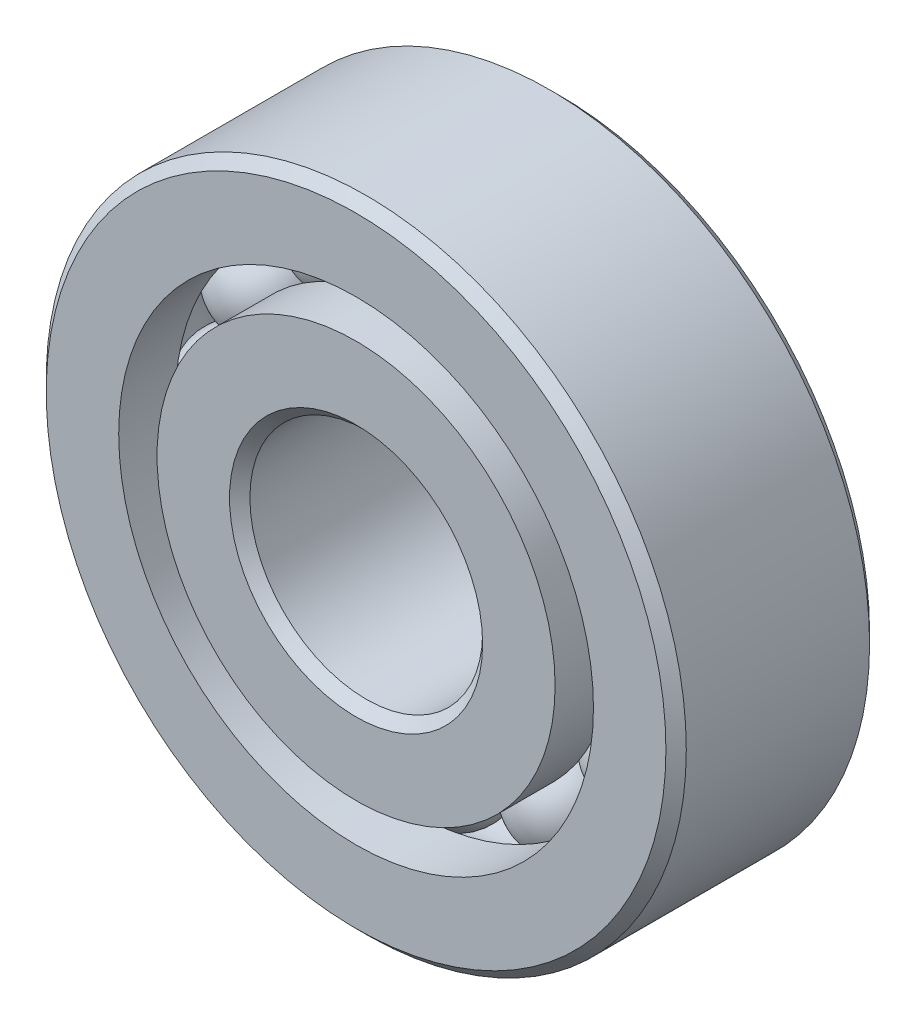
from build123d import *

# Parameters (mm, degrees)
CIRPATTERN1_COUNT = 12


with BuildPart() as part:
    # Sketch1 → Revolve1 (revolve)
    with BuildSketch(Plane(origin=(0, 0, 0), x_dir=(0, 0, -1), z_dir=(1, 0, 0))):
        with BuildLine():
            Line((3.15, 11), (-3.15, 11))
            Line((-3.15, 11), (-3.5, 10.65))
            Line((-3.5, 10.65), (-3.5, 8.159340659))
            Line((-3.5, 8.159340659), (-1.555555556, 8.159340659))
            ThreePointArc((-1.555555556, 8.159340659), (0, 9.189521587), (1.555555556, 8.159340659))
            Line((1.555555556, 8.159340659), (3.5, 8.159340659))
            Line((3.5, 8.159340659), (3.5, 10.65))
            Line((3.5, 10.65), (3.15, 11))
        make_face()
    revolve(axis=Axis((0, 0, 3.5), (0, 0, -1)))


with BuildPart() as body_2:
    # Sketch3 → Revolve3 (revolve)
    with BuildSketch(Plane(origin=(0, 0, 0), x_dir=(0, 0, -1), z_dir=(1, 0, 0))):
        with BuildLine():
            Line((-3.5, 6.840659341), (-1.555555556, 6.840659341))
            ThreePointArc((-1.555555556, 6.840659341), (0, 5.810478413), (1.555555556, 6.840659341))
            Line((1.555555556, 6.840659341), (3.5, 6.840659341))
            Line((3.5, 6.840659341), (3.5, 4.35))
            Line((3.5, 4.35), (3.15, 4))
            Line((3.15, 4), (-3.15, 4))
            Line((-3.15, 4), (-3.5, 4.35))
            Line((-3.5, 4.35), (-3.5, 6.840659341))
        make_face()
    revolve(axis=Axis((0, 0, 3.5), (0, 0, -1)))


with BuildPart() as body_3:
    # Sketch4 → Revolve4 (revolve)
    with BuildSketch(Plane(origin=(0, 0, 0), x_dir=(0, 0, -1), z_dir=(1, 0, 0))):
        with BuildLine():
            Line((-1.689521587, 7.5), (1.689521587, 7.5))
            ThreePointArc((1.689521587, 7.5), (0, 9.189521587), (-1.689521587, 7.5))
        make_face()
    revolve(axis=Axis((0, 7.5, 1.689521587), (0, 0, -1)))


with BuildPart() as cirpattern1_1:
    # CirPattern1: pattern copy
    add(body_3.part.rotate(Axis((0, 0, -3.5), (0, 0, 1)), 1 * 360 / CIRPATTERN1_COUNT))


with BuildPart() as cirpattern1_2:
    # CirPattern1: pattern copy
    add(body_3.part.rotate(Axis((0, 0, -3.5), (0, 0, 1)), 2 * 360 / CIRPATTERN1_COUNT))


with BuildPart() as cirpattern1_3:
    # CirPattern1: pattern copy
    add(body_3.part.rotate(Axis((0, 0, -3.5), (0, 0, 1)), 3 * 360 / CIRPATTERN1_COUNT))


with BuildPart() as cirpattern1_4:
    # CirPattern1: pattern copy
    add(body_3.part.rotate(Axis((0, 0, -3.5), (0, 0, 1)), 4 * 360 / CIRPATTERN1_COUNT))


with BuildPart() as cirpattern1_5:
    # CirPattern1: pattern copy
    add(body_3.part.rotate(Axis((0, 0, -3.5), (0, 0, 1)), 5 * 360 / CIRPATTERN1_COUNT))


with BuildPart() as cirpattern1_6:
    # CirPattern1: pattern copy
    add(body_3.part.rotate(Axis((0, 0, -3.5), (0, 0, 1)), 6 * 360 / CIRPATTERN1_COUNT))


with BuildPart() as cirpattern1_7:
    # CirPattern1: pattern copy
    add(body_3.part.rotate(Axis((0, 0, -3.5), (0, 0, 1)), 7 * 360 / CIRPATTERN1_COUNT))


with BuildPart() as cirpattern1_8:
    # CirPattern1: pattern copy
    add(body_3.part.rotate(Axis((0, 0, -3.5), (0, 0, 1)), 8 * 360 / CIRPATTERN1_COUNT))


with BuildPart() as cirpattern1_9:
    # CirPattern1: pattern copy
    add(body_3.part.rotate(Axis((0, 0, -3.5), (0, 0, 1)), 9 * 360 / CIRPATTERN1_COUNT))


with BuildPart() as cirpattern1_10:
    # CirPattern1: pattern copy
    add(body_3.part.rotate(Axis((0, 0, -3.5), (0, 0, 1)), 10 * 360 / CIRPATTERN1_COUNT))


with BuildPart() as cirpattern1_11:
    # CirPattern1: pattern copy
    add(body_3.part.rotate(Axis((0, 0, -3.5), (0, 0, 1)), 11 * 360 / CIRPATTERN1_COUNT))


solid = Compound([part.part, body_2.part, body_3.part, cirpattern1_1.part, cirpattern1_2.part, cirpattern1_3.part, cirpattern1_4.part, cirpattern1_5.part, cirpattern1_6.part, cirpattern1_7.part, cirpattern1_8.part, cirpattern1_9.part, cirpattern1_10.part, cirpattern1_11.part])
